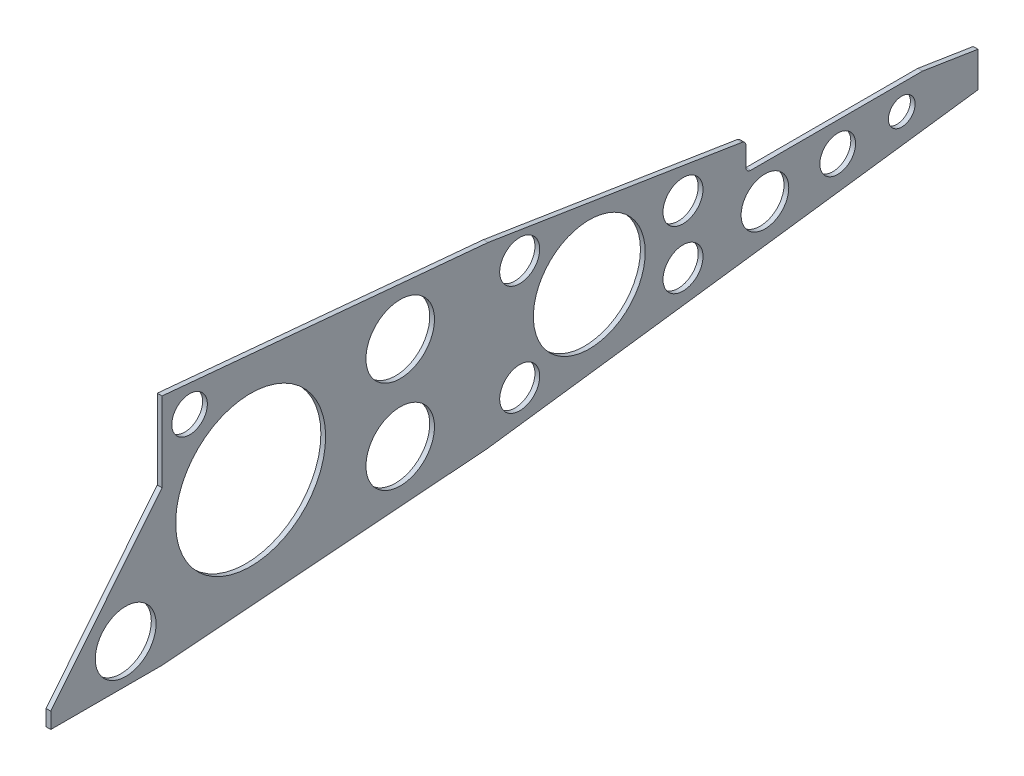
from build123d import *

# Parameters (mm, degrees)
BOSS_EXTRUDE1_DEPTH      = 1.5
BOSS_EXTRUDE1_DEPTH_BACK = 1.5
SKETCH3_W                = 152
SKETCH3_H                = 25
CUT_EXTRUDE1_DEPTH       = 520.533194562
SKETCH4_R                = 19.119387796
SKETCH4_R_2              = 47.191393473
SKETCH4_R_3              = 35.18699184
SKETCH4_R_4              = 12.586978738
SKETCH4_R_5              = 11.189603354
SKETCH4_R_6              = 21.557380713
SKETCH4_R_7              = 14.984143728
SKETCH4_R_8              = 11.239174992
SKETCH4_R_9              = 8.41496245
CUT_EXTRUDE2_DEPTH       = 10
FILLET1_R                = 3


with BuildPart() as part:
    # Sketch2 → Boss-Extrude1 (new, two sides: drawn at the far end of the back side and taken through both)
    with BuildSketch(Plane(origin=(0, 0, 0), x_dir=(0, 0, -1), z_dir=(1, 0, 0)).offset(-BOSS_EXTRUDE1_DEPTH_BACK)):
        Polygon((0, 67.22485033), (205.165503831, 48.288859026), (513.4, -0.530689138), (513.4, -22.650154351), (205.250409944, -63.717607751), (0, -79.537288439), (-70, -79.537288439), (-70, -69.537288439), (0, 17.22485033), align=None)
    extrude(amount=BOSS_EXTRUDE1_DEPTH + BOSS_EXTRUDE1_DEPTH_BACK)

    # Sketch3 → Cut-Extrude1 (cut, through all)
    with BuildSketch(Plane(origin=(1.5, 0, 0), x_dir=(0, 0, -1), z_dir=(1, 0, 0))):
        with Locations((443.4, 17.5)):
            Rectangle(SKETCH3_W, SKETCH3_H)
    extrude(amount=-CUT_EXTRUDE1_DEPTH, mode=Mode.SUBTRACT)

    # Sketch4 → Cut-Extrude2 (cut)
    with BuildSketch(Plane(origin=(1.5, 0, 0), x_dir=(0, 0, -1), z_dir=(1, 0, 0))):
        with Locations((-22.865600385, -55.069339131)):
            Circle(SKETCH4_R)
        with Locations((55.752747866, -6.379566635)):
            Circle(SKETCH4_R_2)
        with Locations((268.826339435, -6.379566635)):
            Circle(SKETCH4_R_3)
        with Locations((225.050213704, 28.462655886)):
            Circle(SKETCH4_R_4)
        with Locations((17.336964062, 48.563938109)):
            Circle(SKETCH4_R_5)
        with Locations((225.050213704, -40.775093995)):
            Circle(SKETCH4_R_4)
        with Locations((327.790100624, -26.927544019)):
            Circle(SKETCH4_R_4)
        with Locations((327.790100624, 9.701459144)):
            Circle(SKETCH4_R_4)
        with Locations((149.867646424, 23.293890716)):
            Circle(SKETCH4_R_6)
        with Locations((149.867646424, -35.180680846)):
            Circle(SKETCH4_R_6)
        with Locations((379.3514003, -16.442535715)):
            Circle(SKETCH4_R_7)
        with Locations((425.129239545, -13.376077584)):
            Circle(SKETCH4_R_8)
        with Locations((465.431260698, -10.528652176)):
            Circle(SKETCH4_R_9)
    extrude(amount=-CUT_EXTRUDE2_DEPTH, mode=Mode.SUBTRACT)

    # Fillet1
    fillet1_edges = [part.edges().sort_by_distance(p)[0] for p in [
        (0, 5, -367.4),
        (0, 22.593439149, -367.4),
    ]]
    fillet(fillet1_edges, radius=FILLET1_R)


solid = part.part
